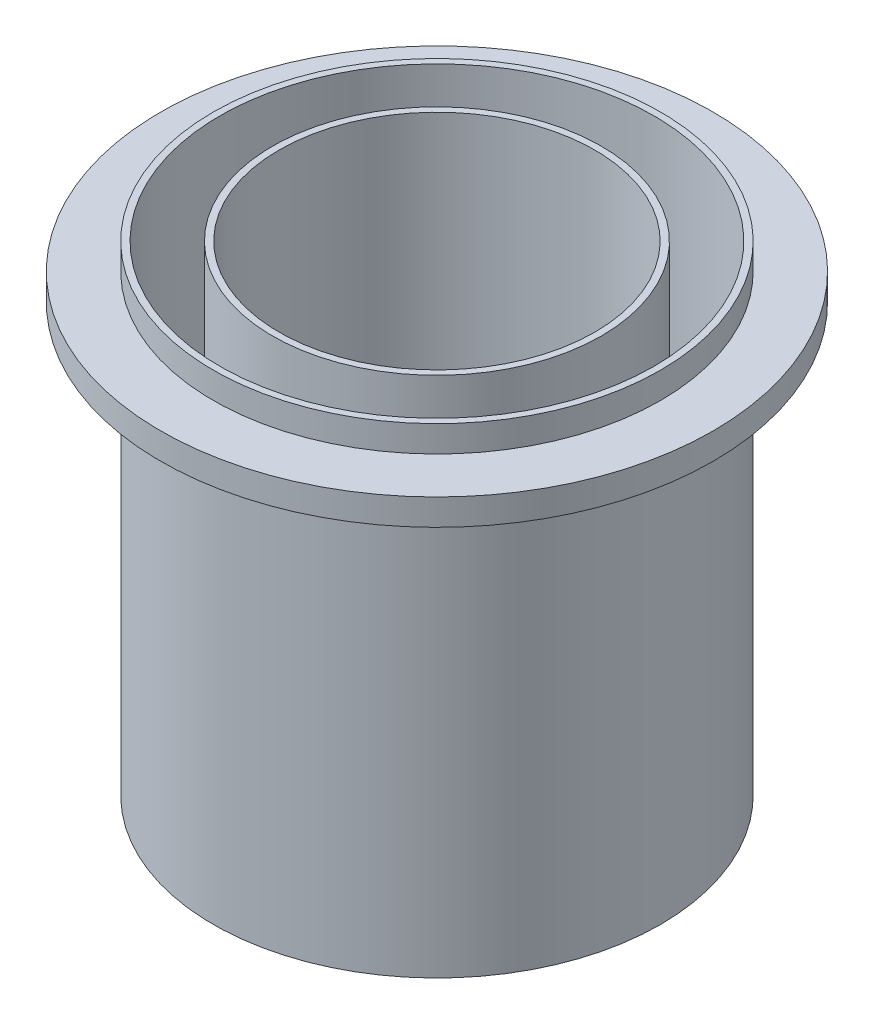
from build123d import *

# Parameters (mm, degrees)
SKETCH2_R          = 3.175
CUT_EXTRUDE1_DEPTH = 2.5875
CIRPATTERN1_COUNT  = 6


with BuildPart() as part:
    # Sketch1 → Revolve1 (revolve)
    with BuildSketch(Plane.XY):
        Polygon((53.975, 0), (30.744042103, 0), (0, 0), (0, 1.5875), (38.1, 1.5875), (38.1, 115.8875), (39.6875, 115.8875), (39.6875, 1.5875), (52.3875, 1.5875), (52.3875, 115.8875), (53.975, 115.8875), (53.975, 109.5375), (66.675, 109.5375), (66.675, 103.1875), (53.975, 103.1875), align=None)
    revolve(axis=Axis((0, -554.392583441, 0), (0, 1, 0)))

    # Sketch2 → Cut-Extrude1 (cut, through all)
    with BuildSketch(Plane(origin=(0, 1.5875, 0), x_dir=(1, 0, 0), z_dir=(0, 1, 0))):
        with Locations(Location((0, 19.05, 0), (0, 0, 180))):  # turned: the seam where the file's is
            Circle(SKETCH2_R)
    cut_extrude1 = extrude(amount=-CUT_EXTRUDE1_DEPTH, mode=Mode.SUBTRACT)

    # CirPattern1: Cut-Extrude1 ×6 about axis
    cirpattern1_axis = Axis((0, 0, 0), (0, 1, 0))
    for i in range(1, CIRPATTERN1_COUNT):
        add(cut_extrude1.rotate(cirpattern1_axis, i * 360 / CIRPATTERN1_COUNT), mode=Mode.SUBTRACT)


solid = part.part
